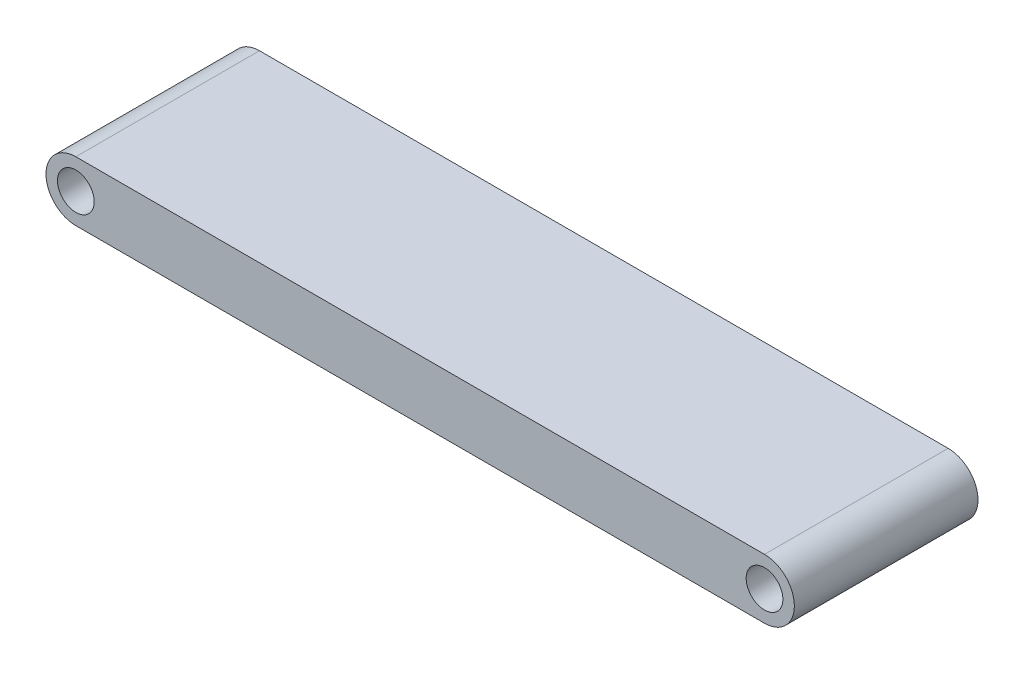
from build123d import *

# Parameters (mm, degrees)
SZKIC1_R                    = 4
DODANIE_WYCI_GNI_CIE1_DEPTH = 40


with BuildPart() as part:
    # Szkic1 → Dodanie-wyciągnięcie1 (new body)
    with BuildSketch(Plane.XY):
        with BuildLine():
            Line((-3.355283808, 6.5), (146.644716192, 6.5))
            ThreePointArc((146.644716192, 6.5), (153.144716192, 0), (146.644716192, -6.5))
            Line((146.644716192, -6.5), (-3.355283808, -6.5))
            ThreePointArc((-3.355283808, -6.5), (-9.855283808, 0), (-3.355283808, 6.5))
        make_face()
        with Locations((-3.355283808, 0)):
            Circle(SZKIC1_R, mode=Mode.SUBTRACT)
        with Locations((146.644716192, 0)):
            Circle(SZKIC1_R, mode=Mode.SUBTRACT)
    extrude(amount=DODANIE_WYCI_GNI_CIE1_DEPTH)


solid = part.part
